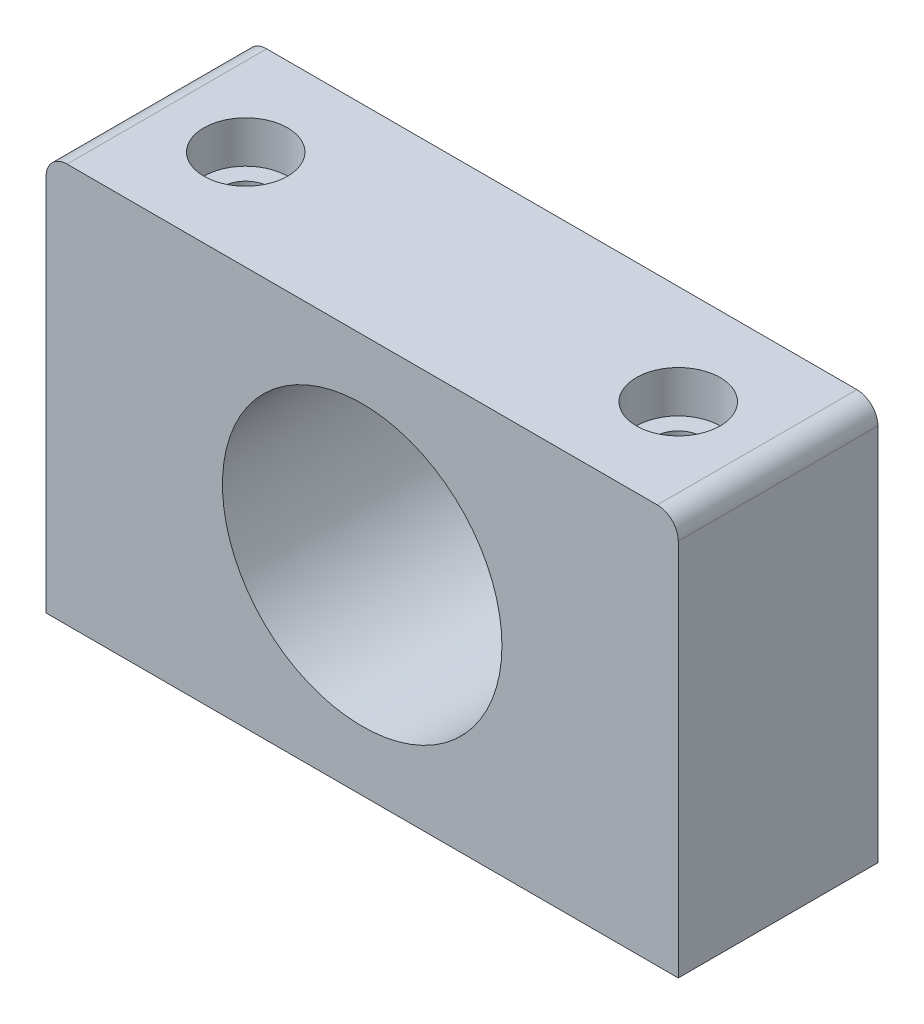
from build123d import *

# Parameters (mm, degrees)
SKETCH1_W                      = 60.325
SKETCH1_H                      = 19.05
BOSS_EXTRUDE1_DEPTH            = 38.1
SKETCH2_R                      = 13.335
CUT_EXTRUDE1_DEPTH             = 20.05
CBORE_FOR_M4_SHCS1_D           = 4.5
CBORE_FOR_M4_SHCS1_CBORE_D     = 8
CBORE_FOR_M4_SHCS1_CBORE_DEPTH = 4
FILLET1_R                      = 2


with BuildPart() as part:
    # Sketch1 → Boss-Extrude1 (new body)
    with BuildSketch(Plane(origin=(0, 0, 0), x_dir=(1, 0, 0), z_dir=(0, 1, 0))):
        Rectangle(SKETCH1_W, SKETCH1_H)
    extrude(amount=BOSS_EXTRUDE1_DEPTH)

    # Sketch2 → Cut-Extrude1 (cut, through all)
    with BuildSketch(Plane.XY.offset(9.525)):
        with Locations((0, 19.05)):
            Circle(SKETCH2_R)
    extrude(amount=-CUT_EXTRUDE1_DEPTH, mode=Mode.SUBTRACT)

    # CBORE for M4 SHCS1 (through all)
    with Locations(Plane(origin=(0, 38.1, 0), x_dir=(1, 0, 0), z_dir=(0, 1, 0))):
        with Locations((-20.6375, 0), (20.6375, 0)):
            CounterBoreHole(CBORE_FOR_M4_SHCS1_D / 2, CBORE_FOR_M4_SHCS1_CBORE_D / 2, CBORE_FOR_M4_SHCS1_CBORE_DEPTH)

    # Fillet1
    fillet1_edges = [part.edges().sort_by_distance(p)[0] for p in [
        (-30.1625, 38.1, 0),
        (30.1625, 38.1, 0),
    ]]
    fillet(fillet1_edges, radius=FILLET1_R)


solid = part.part
